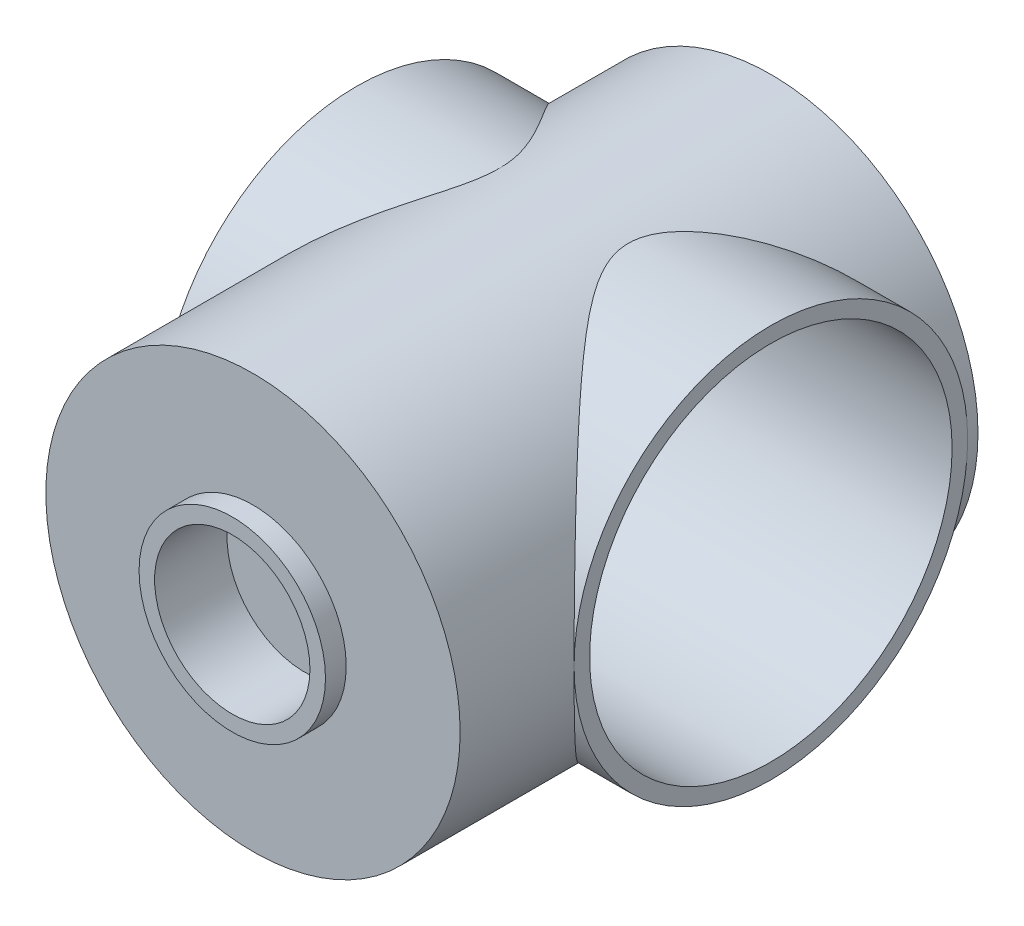
from build123d import *

# Parameters (mm, degrees)
SKETCH1_R           = 20
BOSS_EXTRUDE1_DEPTH = 50
SKETCH2_R           = 19
BOSS_EXTRUDE2_DEPTH = 20
SKETCH4_R           = 17.5
CUT_EXTRUDE1_DEPTH  = 40
SKETCH5_R           = 7.5
CUT_EXTRUDE2_DEPTH  = 5
SKETCH6_R           = 9
SKETCH6_R_2         = 7.5
BOSS_EXTRUDE3_DEPTH = 2


with BuildPart() as part:
    # Sketch1 → Boss-Extrude1 (new body)
    with BuildSketch(Plane.XY):
        Circle(SKETCH1_R)
    extrude(amount=BOSS_EXTRUDE1_DEPTH)

    # Sketch2 → Boss-Extrude2 (add, symmetric)
    with BuildSketch(Plane(origin=(0, 0, 0), x_dir=(0, 0, -1), z_dir=(1, 0, 0))):
        with Locations((-20, 0)):
            Circle(SKETCH2_R)
    extrude(amount=BOSS_EXTRUDE2_DEPTH, both=True)

    # Sketch4 → Cut-Extrude1 (cut)
    with BuildSketch(Plane(origin=(20, 0, 0), x_dir=(0, 0, -1), z_dir=(1, 0, 0))):
        with Locations((-20, 0)):
            Circle(SKETCH4_R)
    extrude(amount=-CUT_EXTRUDE1_DEPTH, mode=Mode.SUBTRACT)

    # Sketch5 → Cut-Extrude2 (cut)
    with BuildSketch(Plane.XY.offset(50)):
        Circle(SKETCH5_R)
    extrude(amount=-CUT_EXTRUDE2_DEPTH, mode=Mode.SUBTRACT)

    # Sketch6 → Boss-Extrude3 (add)
    with BuildSketch(Plane.XY.offset(50)):
        Circle(SKETCH6_R)
        Circle(SKETCH6_R_2, mode=Mode.SUBTRACT)
    extrude(amount=BOSS_EXTRUDE3_DEPTH)


solid = part.part
